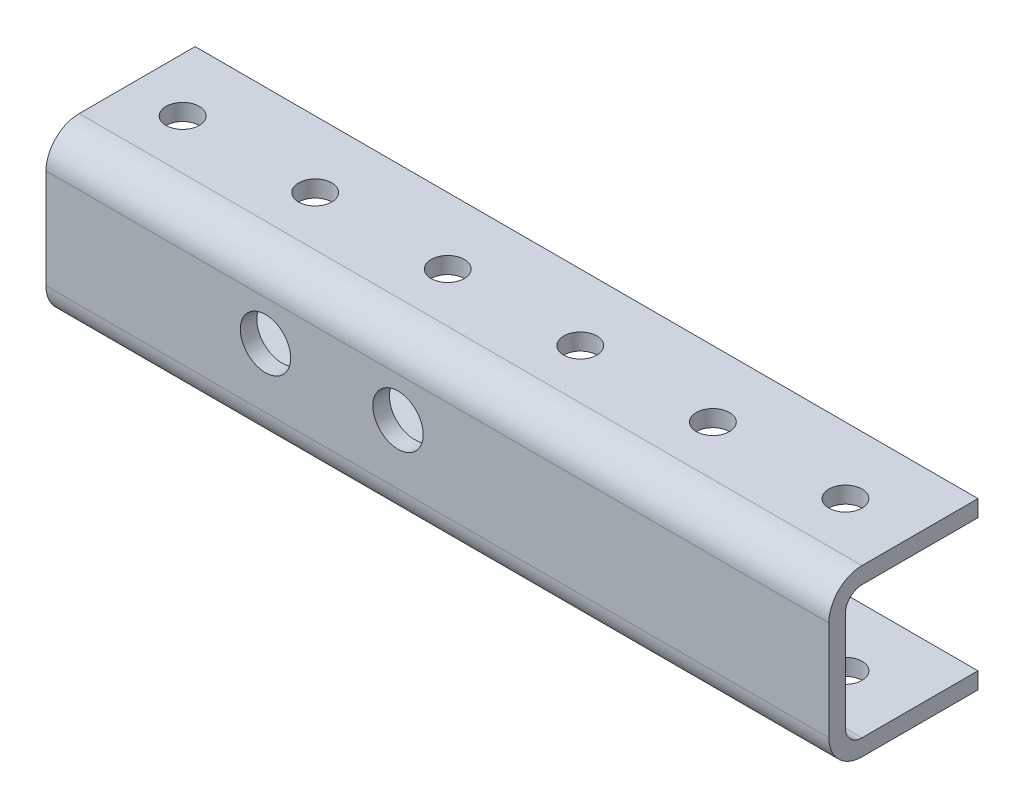
from build123d import *

# Parameters (mm, degrees)
SKETCH1_W               = 889
SKETCH1_H               = 31.75
EXTRUDE1_DEPTH          = 28.575
EXTRUDE2_REACH          = 891.702
SKETCH2_W               = 25.4
SKETCH2_H               = 25.4
HOLE1_D                 = 6.35
HOLE1_DEPTH             = 3.175
LPATTERN1_COUNT         = 35
LPATTERN1_PITCH         = 25.4
HOLE2_D                 = 9.652
LPATTERN2_COUNT         = 12
LPATTERN2_PITCH         = 25.4
HOLE3_D                 = 9.652
HOLE4_D                 = 9.652
LPATTERN3_COUNT         = 12
LPATTERN3_PITCH         = 25.4
HOLE5_D                 = 3.175
HOLE6_D                 = 6.35
LPATTERN4_COUNT         = 35
LPATTERN4_PITCH         = 25.4
FILLET1_R               = 3.175
FILLET2_R               = 3.175
FILLET3_R               = 6.35
FILLET4_R               = 6.35
CUT_EXTRUDE4_DEPTH      = 77
CUT_EXTRUDE4_DEPTH_BACK = 92
SKETCH15_W              = 799.570911011
SKETCH15_H              = 54.502378411
SKETCH15_R              = 3.175


with BuildPart() as part:
    # Sketch1 → Extrude1 (new body)
    with BuildSketch(Plane.XY.offset(3.175)):
        with Locations((428.480011997, 8.672957166)):
            Rectangle(SKETCH1_W, SKETCH1_H)
    extrude(amount=-EXTRUDE1_DEPTH)

    # Sketch2 → Extrude2 (cut, up to next)
    with BuildSketch(Plane.ZY.offset(16.019988003), mode=Mode.PRIVATE) as extrude2_sk1:
        with Locations((-12.7, 8.672957166)):
            Rectangle(SKETCH2_W, SKETCH2_H)
    extrude2_tool1 = extrude(extrude2_sk1.sketch, amount=-EXTRUDE2_REACH, mode=Mode.PRIVATE) & part.part
    add(extrude2_tool1.solids().sort_by_distance((-16.019988, 8.672957, -12.7))[0], mode=Mode.SUBTRACT)

    # Hole1
    with Locations(Plane(origin=(0, 24.547957166, 0), x_dir=(-1, 0, 0), z_dir=(0, 1, 0))):
        with Locations((3.319988003, -12.7)):
            hole1 = Hole(HOLE1_D / 2, depth=HOLE1_DEPTH)

    # LPattern1: Hole1 ×35
    with Locations(*[(i * LPATTERN1_PITCH, 0, 0) for i in range(1, LPATTERN1_COUNT)]):
        add(hole1, mode=Mode.SUBTRACT)

    # Hole2 (through all)
    with Locations(Plane.XY.offset(3.175)):
        with Locations((66.530011997, 10.577957166)):
            hole2 = Hole(HOLE2_D / 2)

    # LPattern2: Hole2 ×12, 8 skipped
    with Locations(*[(i * LPATTERN2_PITCH, 0, 0) for i in range(1, LPATTERN2_COUNT) if i not in (2, 3, 4, 5, 6, 7, 8, 9)]):
        add(hole2, mode=Mode.SUBTRACT)

    # Hole3 (through all)
    with Locations(Plane.XY.offset(3.175)):
        with Locations((428.480011997, 6.767957166)):
            Hole(HOLE3_D / 2)

    # Hole4 (through all)
    with Locations(Plane.XY.offset(3.175)):
        with Locations((511.030011997, 10.577957166)):
            hole4 = Hole(HOLE4_D / 2)

    # LPattern3: Hole4 ×12, 8 skipped
    with Locations(*[(i * LPATTERN3_PITCH, 0, 0) for i in range(1, LPATTERN3_COUNT) if i not in (2, 3, 4, 5, 6, 7, 8, 9)]):
        add(hole4, mode=Mode.SUBTRACT)

    # Hole5 (through all)
    with Locations(Plane.XY.offset(3.175)):
        with Locations((669.780011997, 8.672957166)):
            Hole(HOLE5_D / 2)

    # Hole6 (through all)
    with Locations(Plane(origin=(0, -4.027042834, 0), x_dir=(-1, 0, 0), z_dir=(0, 1, 0))):
        with Locations((3.319988003, -12.7)):
            hole6 = Hole(HOLE6_D / 2)

    # LPattern4: Hole6 ×35
    with Locations(*[(i * LPATTERN4_PITCH, 0, 0) for i in range(1, LPATTERN4_COUNT)]):
        add(hole6, mode=Mode.SUBTRACT)

    # Fillet1
    fillet1_edges = [part.edges().sort_by_distance(p)[0] for p in [
        (428.480011997, 21.372957166, 0),
    ]]
    fillet(fillet1_edges, radius=FILLET1_R)

    # Fillet2
    fillet2_edges = [part.edges().sort_by_distance(p)[0] for p in [
        (428.480011997, -4.027042834, 0),
    ]]
    fillet(fillet2_edges, radius=FILLET2_R)

    # Fillet3
    fillet3_edges = [part.edges().sort_by_distance(p)[0] for p in [
        (428.480011997, -7.202042834, 3.175),
    ]]
    fillet(fillet3_edges, radius=FILLET3_R)

    # Fillet4
    fillet4_edges = [part.edges().sort_by_distance(p)[0] for p in [
        (428.480011997, 24.547957166, 3.175),
    ]]
    fillet(fillet4_edges, radius=FILLET4_R)

    # Sketch15 → Cut-Extrude4 (cut, two sides: drawn at the far end of the back side and taken through both)
    with BuildSketch(Plane(origin=(0, 24.547957166, 0), x_dir=(1, 0, 0), z_dir=(0, 1, 0)).offset(-CUT_EXTRUDE4_DEPTH_BACK)):
        with Locations((323.194556492, -1.851189205)):
            Rectangle(SKETCH15_W, SKETCH15_H)
        with Locations((-3.319988003, 12.7)):
            Circle(SKETCH15_R, mode=Mode.SUBTRACT)
        with Locations((47.480011997, 12.7)):
            Circle(SKETCH15_R, mode=Mode.SUBTRACT)
        with Locations((98.280011997, 12.7)):
            Circle(SKETCH15_R, mode=Mode.SUBTRACT)
        with Locations((149.080011997, 12.7)):
            Circle(SKETCH15_R, mode=Mode.SUBTRACT)
        with Locations((199.880011997, 12.7)):
            Circle(SKETCH15_R, mode=Mode.SUBTRACT)
        with Locations((250.680011997, 12.7)):
            Circle(SKETCH15_R, mode=Mode.SUBTRACT)
        with Locations((301.480011997, 12.7)):
            Circle(SKETCH15_R, mode=Mode.SUBTRACT)
        with Locations((326.880011997, 12.7)):
            Circle(SKETCH15_R, mode=Mode.SUBTRACT)
        with Locations((352.280011997, 12.7)):
            Circle(SKETCH15_R, mode=Mode.SUBTRACT)
        with Locations((377.680011997, 12.7)):
            Circle(SKETCH15_R, mode=Mode.SUBTRACT)
        with Locations((403.080011997, 12.7)):
            Circle(SKETCH15_R, mode=Mode.SUBTRACT)
        with Locations((428.480011997, 12.7)):
            Circle(SKETCH15_R, mode=Mode.SUBTRACT)
        with Locations((453.880011997, 12.7)):
            Circle(SKETCH15_R, mode=Mode.SUBTRACT)
        with Locations((479.280011997, 12.7)):
            Circle(SKETCH15_R, mode=Mode.SUBTRACT)
        with Locations((504.680011997, 12.7)):
            Circle(SKETCH15_R, mode=Mode.SUBTRACT)
        with Locations((530.080011997, 12.7)):
            Circle(SKETCH15_R, mode=Mode.SUBTRACT)
        with Locations((555.480011997, 12.7)):
            Circle(SKETCH15_R, mode=Mode.SUBTRACT)
        with Locations((580.880011997, 12.7)):
            Circle(SKETCH15_R, mode=Mode.SUBTRACT)
        with Locations((606.280011997, 12.7)):
            Circle(SKETCH15_R, mode=Mode.SUBTRACT)
        with Locations((631.680011997, 12.7)):
            Circle(SKETCH15_R, mode=Mode.SUBTRACT)
        with Locations((657.080011997, 12.7)):
            Circle(SKETCH15_R, mode=Mode.SUBTRACT)
        with Locations((682.480011997, 12.7)):
            Circle(SKETCH15_R, mode=Mode.SUBTRACT)
        with Locations((707.880011997, 12.7)):
            Circle(SKETCH15_R, mode=Mode.SUBTRACT)
    extrude(amount=CUT_EXTRUDE4_DEPTH + CUT_EXTRUDE4_DEPTH_BACK, mode=Mode.SUBTRACT)


solid = part.part
